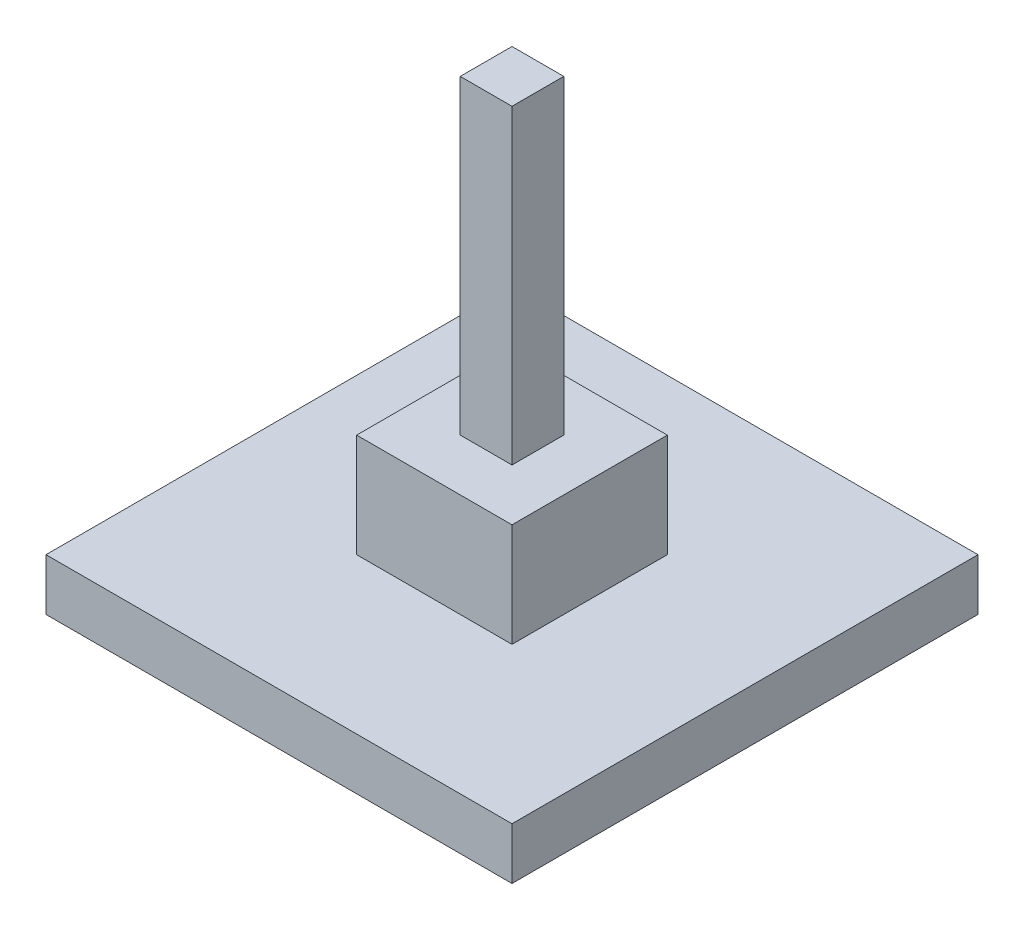
from build123d import *

# Parameters (mm, degrees)
SKETCH1_W           = 76.2
SKETCH1_H           = 76.2
BOSS_EXTRUDE1_DEPTH = 685.8
SKETCH1_3_W         = 228.6
SKETCH1_3_H         = 228.6
SKETCH1_3_W_2       = 76.2
SKETCH1_3_H_2       = 76.2
BOSS_EXTRUDE2_DEPTH = 228.6
SKETCH1_4_W         = 685.8
SKETCH1_4_H         = 685.8
SKETCH1_4_W_2       = 228.6
SKETCH1_4_H_2       = 228.6
BOSS_EXTRUDE3_DEPTH = 76.2


with BuildPart() as part:
    # Sketch1 → Boss-Extrude1 (new body)
    with BuildSketch(Plane(origin=(0, 0, 0), x_dir=(1, 0, 0), z_dir=(0, 1, 0))):
        Rectangle(SKETCH1_W, SKETCH1_H)
    extrude(amount=BOSS_EXTRUDE1_DEPTH)

    # Sketch1_3 → Boss-Extrude2 (add)
    with BuildSketch(Plane(origin=(0, 0, 0), x_dir=(1, 0, 0), z_dir=(0, 1, 0))):
        Rectangle(SKETCH1_3_W, SKETCH1_3_H)
        Rectangle(SKETCH1_3_W_2, SKETCH1_3_H_2, mode=Mode.SUBTRACT)
    extrude(amount=BOSS_EXTRUDE2_DEPTH)

    # Sketch1_4 → Boss-Extrude3 (add)
    with BuildSketch(Plane(origin=(0, 0, 0), x_dir=(1, 0, 0), z_dir=(0, 1, 0))):
        Rectangle(SKETCH1_4_W, SKETCH1_4_H)
        Rectangle(SKETCH1_4_W_2, SKETCH1_4_H_2, mode=Mode.SUBTRACT)
    extrude(amount=BOSS_EXTRUDE3_DEPTH)


solid = part.part
